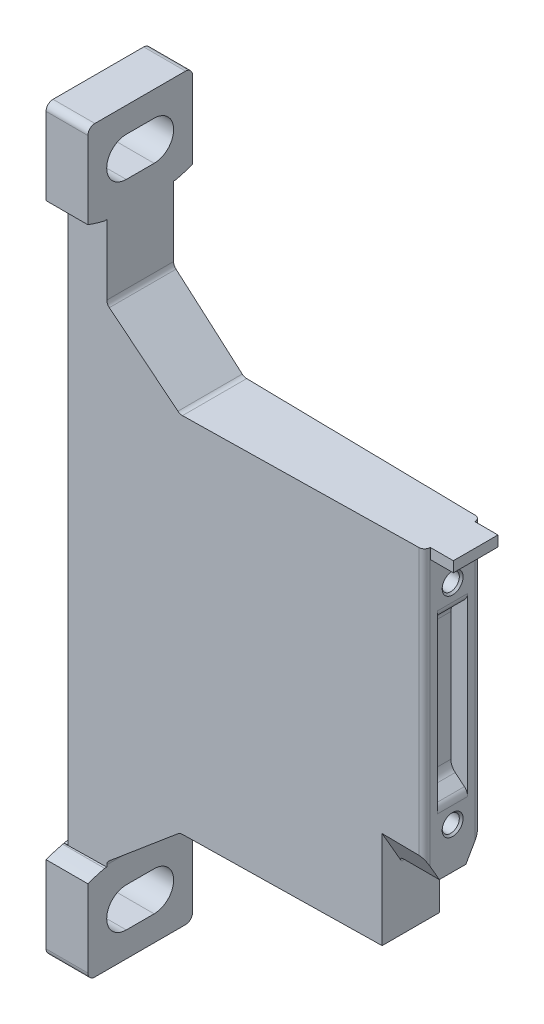
from build123d import *

# Parameters (mm, degrees)
BOSS_EXTRUDE1_DEPTH      = 51
CUT_EXTRUDE1_DEPTH       = 10
CUT_EXTRUDE1_DEPTH_BACK  = 10
CUT_EXTRUDE2_DEPTH       = 10
CUT_EXTRUDE2_DEPTH_BACK  = 10
CUT_EXTRUDE3_DEPTH       = 10
CUT_EXTRUDE3_DEPTH_BACK  = 10
CUT_EXTRUDE4_DEPTH       = 0.5
CUT_EXTRUDE4_DEPTH_BACK  = 0.5
CUT_EXTRUDE5_DEPTH       = 80.4
CUT_EXTRUDE6_DEPTH       = 1.5
CUT_EXTRUDE6_DEPTH_BACK  = 1.5
SKETCH8_W                = 3.8
SKETCH8_H                = 1.5
BOSS_EXTRUDE2_DEPTH      = 3.2
BOSS_EXTRUDE2_DEPTH_BACK = 3.2
CUT_EXTRUDE7_DEPTH       = 2.15
CUT_EXTRUDE7_DEPTH_BACK  = 2.15
CUT_EXTRUDE8_DEPTH       = 6
CUT_EXTRUDE8_DEPTH_BACK  = 6


with BuildPart() as part:
    # Sketch1 → Boss-Extrude1 (new body)
    with BuildSketch(Plane(origin=(0, 0, 0), x_dir=(0, 0, -1), z_dir=(1, 0, 0))):
        with BuildLine():
            Line((-7.5, 105), (-7.5, 93.91788212))
            ThreePointArc((-7.5, 93.91788212), (-6.261006558, 93.509722693), (-5, 93.175714714))
            Line((-5, 93.175714714), (-5, 12.824285286))
            ThreePointArc((-5, 12.824285286), (-6.261006558, 12.490277307), (-7.5, 12.08211788))
            Line((-7.5, 12.08211788), (-7.5, 1))
            ThreePointArc((-7.5, 1), (-7.207106781, 0.292893219), (-6.5, 0))
            Line((-6.5, 0), (6.5, 0))
            ThreePointArc((6.5, 0), (7.207106781, 0.292893219), (7.5, 1))
            Line((7.5, 1), (7.5, 12.08211788))
            ThreePointArc((7.5, 12.08211788), (6.261006558, 12.490277307), (5, 12.824285286))
            Line((5, 12.824285286), (5, 93.175714714))
            ThreePointArc((5, 93.175714714), (6.261006558, 93.509722693), (7.5, 93.91788212))
            Line((7.5, 93.91788212), (7.5, 105))
            ThreePointArc((7.5, 105), (7.207106781, 105.707106781), (6.5, 106))
            Line((6.5, 106), (-6.5, 106))
            ThreePointArc((-6.5, 106), (-7.207106781, 105.707106781), (-7.5, 105))
        make_face()
    extrude(amount=BOSS_EXTRUDE1_DEPTH)

    # Sketch2 → Cut-Extrude1 (cut, two sides)
    with BuildSketch(Plane.XY) as cut_extrude1_sk:
        with BuildLine():
            Line((6, 155.065), (6, 83.209033859))
            ThreePointArc((6, 83.209033859), (6.093692213, 82.786415598), (6.35721239, 82.442989416))
            Line((6.35721239, 82.442989416), (16.021182625, 74.333955557))
            ThreePointArc((16.021182625, 74.333955557), (16.321950091, 74.160307379), (16.663970234, 74.1))
            Line((16.663970234, 74.1), (95, 74.1))
            Line((95, 74.1), (95, 32.2))
            Line((95, 32.2), (45.8, 32.2))
            ThreePointArc((45.8, 32.2), (45.092893219, 31.907106781), (44.8, 31.2))
            Line((44.8, 31.2), (44.8, 22.1))
            Line((44.8, 22.1), (16.663970234, 22.1))
            ThreePointArc((16.663970234, 22.1), (16.321950091, 22.039692621), (16.021182625, 21.866044443))
            Line((16.021182625, 21.866044443), (6.285769912, 13.697063227))
            ThreePointArc((6.285769912, 13.697063227), (6.07495377, 13.422322282), (6, 13.084227672))
            Line((6, 13.084227672), (6, -150))
            Line((6, -150), (100, -150))
            Line((100, -150), (100, 155.065))
            Line((100, 155.065), (6, 155.065))
        make_face()
    extrude(amount=CUT_EXTRUDE1_DEPTH, mode=Mode.SUBTRACT)
    extrude(cut_extrude1_sk.sketch, amount=-CUT_EXTRUDE1_DEPTH_BACK, mode=Mode.SUBTRACT)

    # Sketch3 → Cut-Extrude2 (cut, two sides)
    with BuildSketch(Plane(origin=(0, 0, 0), x_dir=(0, 0, -1), z_dir=(1, 0, 0))) as cut_extrude2_sk:
        with BuildLine():
            Line((-2, 3.6), (2, 3.6))
            ThreePointArc((2, 3.6), (4.799999867, 6.4), (2, 9.2))
            Line((2, 9.2), (-2, 9.2))
            ThreePointArc((-2, 9.2), (-4.799999867, 6.4), (-2, 3.6))
        make_face()
    extrude(amount=CUT_EXTRUDE2_DEPTH, mode=Mode.SUBTRACT)
    extrude(cut_extrude2_sk.sketch, amount=-CUT_EXTRUDE2_DEPTH_BACK, mode=Mode.SUBTRACT)

    # Sketch4 → Cut-Extrude3 (cut, two sides)
    with BuildSketch(Plane(origin=(0, 0, 0), x_dir=(0, 0, -1), z_dir=(1, 0, 0))) as cut_extrude3_sk:
        with BuildLine():
            Line((-2, 96.8), (2, 96.8))
            ThreePointArc((2, 96.8), (4.799999867, 99.6), (2, 102.4))
            Line((2, 102.4), (-2, 102.4))
            ThreePointArc((-2, 102.4), (-4.799999867, 99.6), (-2, 96.8))
        make_face()
    extrude(amount=CUT_EXTRUDE3_DEPTH, mode=Mode.SUBTRACT)
    extrude(cut_extrude3_sk.sketch, amount=-CUT_EXTRUDE3_DEPTH_BACK, mode=Mode.SUBTRACT)

    # Sketch5 → Cut-Extrude4 (cut, two sides)
    with BuildSketch(Plane(origin=(0, 0, 0), x_dir=(0, 0, -1), z_dir=(1, 0, 0))) as cut_extrude4_sk:
        with BuildLine():
            Line((-8, 94.106098468), (-8, 11.893901532))
            ThreePointArc((-8, 11.893901532), (0, 13.4), (8, 11.893901532))
            Line((8, 11.893901532), (8, 94.106098468))
            ThreePointArc((8, 94.106098468), (0, 92.6), (-8, 94.106098468))
        make_face()
    extrude(amount=CUT_EXTRUDE4_DEPTH, mode=Mode.SUBTRACT)
    extrude(cut_extrude4_sk.sketch, amount=-CUT_EXTRUDE4_DEPTH_BACK, mode=Mode.SUBTRACT)

    # Sketch6 → Cut-Extrude5 (cut)
    with BuildSketch(Plane(origin=(0, 12.8, 0), x_dir=(1, 0, 0), z_dir=(0, 1, 0))):
        with BuildLine():
            Line((-7.83333, -20.4458), (56.7096, -20.4458))
            Line((56.7096, -20.4458), (56.7096, 14.6041))
            Line((56.7096, 14.6041), (-7.83333, 14.6041))
            Line((-7.83333, 14.6041), (-7.83333, 5.029470245))
            Line((-7.83333, 5.029470245), (50.013961925, 4.019742008))
            ThreePointArc((50.013961925, 4.019742008), (50.570600359, 3.780591263), (50.8, 3.219863852))
            Line((50.8, 3.219863852), (50.8, -3.219863852))
            ThreePointArc((50.8, -3.219863852), (50.570600359, -3.780591263), (50.013961925, -4.019742008))
            Line((50.013961925, -4.019742008), (-7.83333, -5.029470245))
            Line((-7.83333, -5.029470245), (-7.83333, -20.4458))
        make_face()
    extrude(amount=CUT_EXTRUDE5_DEPTH, mode=Mode.SUBTRACT)

    # Sketch7 → Cut-Extrude6 (cut, two sides)
    with BuildSketch(Plane.XY) as cut_extrude6_sk:
        with BuildLine():
            Line((-49.796416348, 97.062832237), (-49.796416348, 8.937167763))
            Line((-49.796416348, 8.937167763), (3.5, 13.6))
            Line((3.5, 13.6), (14.898143221, 23.164177772))
            ThreePointArc((14.898143221, 23.164177772), (16.101213086, 23.858770483), (17.469293659, 24.1))
            Line((17.469293659, 24.1), (40.8, 24.1))
            ThreePointArc((40.8, 24.1), (42.214213562, 24.685786438), (42.8, 26.1))
            Line((42.8, 26.1), (42.8, 32.2))
            ThreePointArc((42.8, 32.2), (43.385786438, 33.614213562), (44.8, 34.2))
            Line((44.8, 34.2), (45.3, 34.2))
            ThreePointArc((45.3, 34.2), (45.653553391, 34.346446609), (45.8, 34.7))
            Line((45.8, 34.7), (45.8, 42.907575802))
            ThreePointArc((45.8, 42.907575802), (45.244727924, 44.290601913), (43.887238775, 44.905672245))
            Line((43.887238775, 44.905672245), (-0.5, 46.843660943))
            Line((-0.5, 46.843660943), (-0.5, 49.356339057))
            Line((-0.5, 49.356339057), (43.887238775, 51.294327755))
            ThreePointArc((43.887238775, 51.294327755), (45.244727924, 51.909398087), (45.8, 53.292424198))
            Line((45.8, 53.292424198), (45.8, 70.1))
            ThreePointArc((45.8, 70.1), (45.214213562, 71.514213562), (43.8, 72.1))
            Line((43.8, 72.1), (16.396715426, 72.1))
            ThreePointArc((16.396715426, 72.1), (15.028634853, 72.341229517), (13.825564987, 73.035822228))
            Line((13.825564987, 73.035822228), (3.5, 81.7))
            Line((3.5, 81.7), (3.5, 92.4))
            Line((3.5, 92.4), (-49.796416348, 97.062832237))
        make_face()
    extrude(amount=CUT_EXTRUDE6_DEPTH, mode=Mode.SUBTRACT)
    extrude(cut_extrude6_sk.sketch, amount=-CUT_EXTRUDE6_DEPTH_BACK, mode=Mode.SUBTRACT)

    # Sketch8 → Boss-Extrude2 (add, two sides)
    with BuildSketch(Plane.XY) as boss_extrude2_sk:
        with Locations((52.2, 73.35)):
            Rectangle(SKETCH8_W, SKETCH8_H)
    extrude(amount=BOSS_EXTRUDE2_DEPTH)
    extrude(boss_extrude2_sk.sketch, amount=-BOSS_EXTRUDE2_DEPTH_BACK)

    # Sketch9 → Cut-Extrude7 (cut, two sides)
    with BuildSketch(Plane.XY) as cut_extrude7_sk:
        with BuildLine():
            Line((48.4, 62.270122483), (48.4, 43.929877517))
            ThreePointArc((48.4, 43.929877517), (48.563961373, 43.190295559), (49.025121683, 42.589299741))
            Line((49.025121683, 42.589299741), (50.335623893, 41.48965782))
            ThreePointArc((50.335623893, 41.48965782), (50.678200123, 41.043203785), (50.8, 40.493800044))
            Line((50.8, 40.493800044), (55.7133, 36.977251782))
            Line((55.7133, 36.977251782), (55.7133, 69.222748218))
            Line((55.7133, 69.222748218), (50.8, 65.706199956))
            ThreePointArc((50.8, 65.706199956), (50.678200123, 65.156796215), (50.335623893, 64.71034218))
            Line((50.335623893, 64.71034218), (49.025121683, 63.610700259))
            ThreePointArc((49.025121683, 63.610700259), (48.563961373, 63.009704441), (48.4, 62.270122483))
        make_face()
    extrude(amount=CUT_EXTRUDE7_DEPTH, mode=Mode.SUBTRACT)
    extrude(cut_extrude7_sk.sketch, amount=-CUT_EXTRUDE7_DEPTH_BACK, mode=Mode.SUBTRACT)

    # Sketch10 → Cut-Revolve1 (revolve, cut)
    with BuildSketch(Plane.XY):
        Polygon((45.8, 68.1), (45.8, 69.6), (46.0705, 69.3295), (50.5295, 69.3295), (50.8, 69.6), (50.8, 68.1), align=None)
    revolve(axis=Axis((50.8, 68.1, 0), (-1, 0, 0)), mode=Mode.SUBTRACT)

    # Sketch11 → Cut-Revolve2 (revolve, cut)
    with BuildSketch(Plane.XY):
        Polygon((45.8, 38.1), (45.8, 39.6), (46.0705, 39.3295), (50.5295, 39.3295), (50.8, 39.6), (50.8, 38.1), align=None)
    revolve(axis=Axis((50.8, 38.1, 0), (-1, 0, 0)), mode=Mode.SUBTRACT)

    # Sketch12 → Cut-Extrude8 (cut, two sides)
    with BuildSketch(Plane(origin=(50.8, 0, 0), x_dir=(0, 0, -1), z_dir=(1, 0, 0))) as cut_extrude8_sk:
        Polygon((-16.0833, 30.7), (16.9167, 30.7), (16.9167, 58.209687362), (1.322649731, 31.2), (-1.322649731, 31.2), (-16.0833, 56.766196219), align=None)
    extrude(amount=CUT_EXTRUDE8_DEPTH, mode=Mode.SUBTRACT)
    extrude(cut_extrude8_sk.sketch, amount=-CUT_EXTRUDE8_DEPTH_BACK, mode=Mode.SUBTRACT)


solid = part.part
